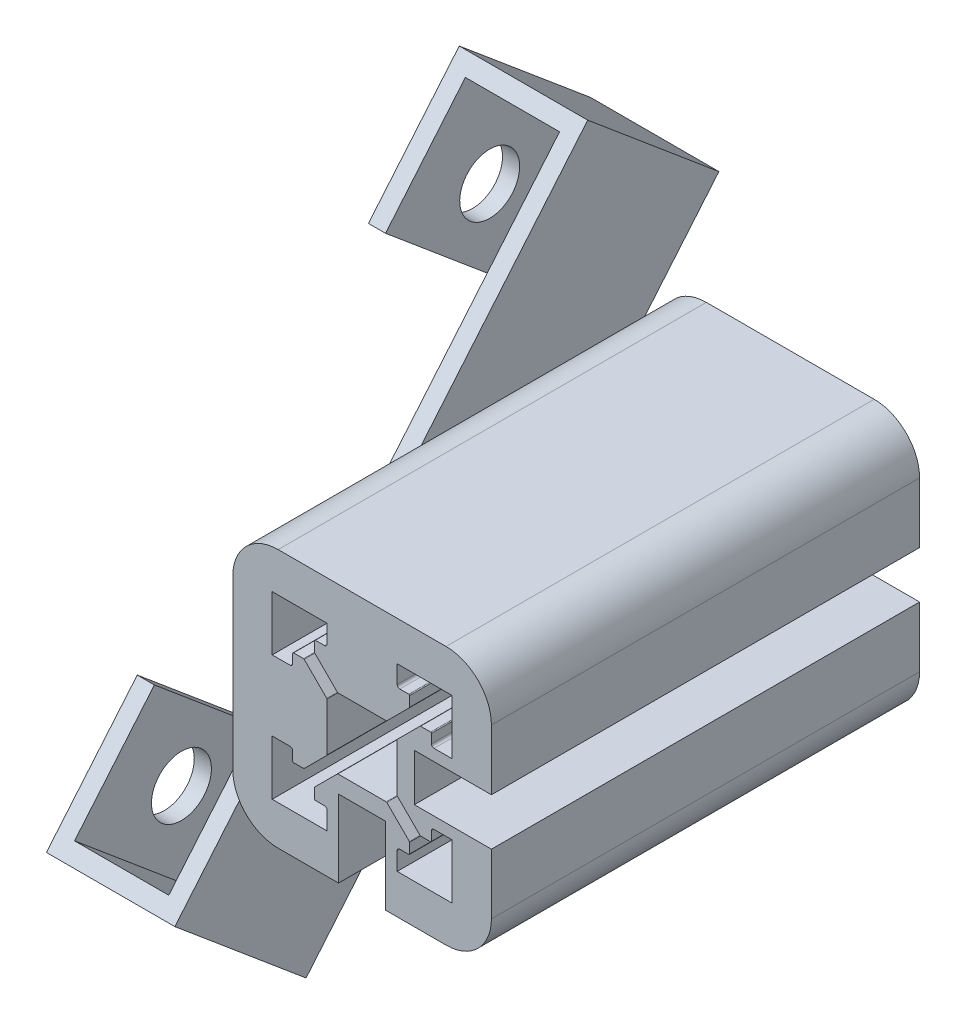
from build123d import *

# Parameters (mm, degrees)
Y_KSEKLIK_EKSTR_ZYON3_DEPTH = 25
Y_KSEKLIK_EKSTR_ZYON4_DEPTH = 15
IZIM11_R                    = 3.5
KES_EKSTR_ZYON3_DEPTH       = 10
KES_EKSTR_ZYON4_DEPTH       = 16
KES_EKSTR_ZYON5_REACH       = 77.444


with BuildPart() as part:
    # Çizim6 → Yükseklik-Ekstrüzyon3 (new, symmetric)
    with BuildSketch(Plane.XY):
        with BuildLine():
            Line((-119.371512251, 18.973770729), (-115.371512251, 18.973770729))
            Line((-115.371512251, 18.973770729), (-110.371512251, 18.973770729))
            Line((-110.371512251, 18.973770729), (-110.371512251, 20.773770729))
            Line((-110.371512251, 20.773770729), (-110.371512251, 26.023770729))
            ThreePointArc((-110.371512251, 26.023770729), (-111.92384631, 29.771436669), (-115.671512251, 31.323770729))
            Line((-115.671512251, 31.323770729), (-120.921512251, 31.323770729))
            Line((-120.921512251, 31.323770729), (-122.721512251, 31.323770729))
            Line((-122.721512251, 31.323770729), (-128.221512251, 31.323770729))
            Line((-128.221512251, 31.323770729), (-130.021512251, 31.323770729))
            Line((-130.021512251, 31.323770729), (-135.271512251, 31.323770729))
            ThreePointArc((-135.271512251, 31.323770729), (-139.019178191, 29.771436669), (-140.571512251, 26.023770729))
            Line((-140.571512251, 26.023770729), (-140.571512251, 20.773770729))
            Line((-140.571512251, 20.773770729), (-140.571512251, 16.223770729))
            Line((-140.571512251, 16.223770729), (-140.571512251, 11.673770729))
            Line((-140.571512251, 11.673770729), (-140.571512251, 6.423770729))
            ThreePointArc((-140.571512251, 6.423770729), (-139.019178191, 2.676104789), (-135.271512251, 1.123770729))
            Line((-135.271512251, 1.123770729), (-130.021512251, 1.123770729))
            Line((-130.021512251, 1.123770729), (-128.221512251, 1.123770729))
            Line((-128.221512251, 1.123770729), (-128.221512251, 6.123770729))
            Line((-128.221512251, 6.123770729), (-128.221512251, 10.123770729))
            Line((-128.221512251, 10.123770729), (-122.721512251, 10.123770729))
            Line((-122.721512251, 10.123770729), (-122.721512251, 6.123770729))
            Line((-122.721512251, 6.123770729), (-122.721512251, 1.123770729))
            Line((-122.721512251, 1.123770729), (-120.921512251, 1.123770729))
            Line((-120.921512251, 1.123770729), (-115.671512251, 1.123770729))
            ThreePointArc((-115.671512251, 1.123770729), (-111.92384631, 2.676104789), (-110.371512251, 6.423770729))
            Line((-110.371512251, 6.423770729), (-110.371512251, 11.673770729))
            Line((-110.371512251, 11.673770729), (-110.371512251, 13.473770729))
            Line((-110.371512251, 13.473770729), (-115.371512251, 13.473770729))
            Line((-115.371512251, 13.473770729), (-119.371512251, 13.473770729))
            Line((-119.371512251, 13.473770729), (-119.371512251, 18.973770729))
        make_face()
        with BuildLine():
            Line((-133.871512251, 20.323770729), (-135.071512251, 20.323770729))
            Line((-135.071512251, 20.323770729), (-135.871512251, 20.323770729))
            Line((-135.871512251, 20.323770729), (-135.971512251, 20.323770729))
            Line((-135.971512251, 20.323770729), (-135.971512251, 26.723770729))
            Line((-135.971512251, 26.723770729), (-129.571512251, 26.723770729))
            Line((-129.571512251, 26.723770729), (-129.571512251, 26.623770729))
            Line((-129.571512251, 26.623770729), (-129.571512251, 25.823770729))
            Line((-129.571512251, 25.823770729), (-129.571512251, 24.623770729))
            ThreePointArc((-129.571512251, 24.623770729), (-129.659380216, 24.411638694), (-129.871512251, 24.323770729))
            Line((-129.871512251, 24.323770729), (-130.921512251, 24.323770729))
            ThreePointArc((-130.921512251, 24.323770729), (-130.992222929, 24.294481407), (-131.021512251, 24.223770729))
            Line((-131.021512251, 24.223770729), (-131.021512251, 23.056613441))
            ThreePointArc((-131.021512251, 23.056613441), (-131.013900204, 23.018345098), (-130.992222929, 22.985902763))
            Line((-130.992222929, 22.985902763), (-128.359380216, 20.353060051))
            ThreePointArc((-128.359380216, 20.353060051), (-128.326937882, 20.331382776), (-128.288669538, 20.323770729))
            Line((-128.288669538, 20.323770729), (-122.654354963, 20.323770729))
            ThreePointArc((-122.654354963, 20.323770729), (-122.61608662, 20.331382776), (-122.583644285, 20.353060051))
            Line((-122.583644285, 20.353060051), (-119.950801573, 22.985902763))
            ThreePointArc((-119.950801573, 22.985902763), (-119.929124298, 23.018345098), (-119.921512251, 23.056613441))
            Line((-119.921512251, 23.056613441), (-119.921512251, 24.223770729))
            ThreePointArc((-119.921512251, 24.223770729), (-119.950801573, 24.294481407), (-120.021512251, 24.323770729))
            Line((-120.021512251, 24.323770729), (-121.071512251, 24.323770729))
            ThreePointArc((-121.071512251, 24.323770729), (-121.283644285, 24.411638694), (-121.371512251, 24.623770729))
            Line((-121.371512251, 24.623770729), (-121.371512251, 25.823770729))
            Line((-121.371512251, 25.823770729), (-121.371512251, 26.323770729))
            Line((-121.371512251, 26.323770729), (-121.371512251, 26.723770729))
            Line((-121.371512251, 26.723770729), (-114.971512251, 26.723770729))
            Line((-114.971512251, 26.723770729), (-114.971512251, 20.323770729))
            Line((-114.971512251, 20.323770729), (-115.371512251, 20.323770729))
            Line((-115.371512251, 20.323770729), (-115.871512251, 20.323770729))
            Line((-115.871512251, 20.323770729), (-117.071512251, 20.323770729))
            ThreePointArc((-117.071512251, 20.323770729), (-117.283644285, 20.411638694), (-117.371512251, 20.623770729))
            Line((-117.371512251, 20.623770729), (-117.371512251, 21.673770729))
            ThreePointArc((-117.371512251, 21.673770729), (-117.400801573, 21.744481407), (-117.471512251, 21.773770729))
            Line((-117.471512251, 21.773770729), (-118.638669538, 21.773770729))
            ThreePointArc((-118.638669538, 21.773770729), (-118.676937882, 21.766158682), (-118.709380216, 21.744481407))
            Line((-118.709380216, 21.744481407), (-121.342222929, 19.111638694))
            ThreePointArc((-121.342222929, 19.111638694), (-121.363900204, 19.07919636), (-121.371512251, 19.040928016))
            Line((-121.371512251, 19.040928016), (-121.371512251, 13.406613441))
            ThreePointArc((-121.371512251, 13.406613441), (-121.363900204, 13.368345098), (-121.342222929, 13.335902763))
            Line((-121.342222929, 13.335902763), (-118.709380216, 10.703060051))
            ThreePointArc((-118.709380216, 10.703060051), (-118.676937882, 10.681382776), (-118.638669538, 10.673770729))
            Line((-118.638669538, 10.673770729), (-117.471512251, 10.673770729))
            ThreePointArc((-117.471512251, 10.673770729), (-117.400801573, 10.703060051), (-117.371512251, 10.773770729))
            Line((-117.371512251, 10.773770729), (-117.371512251, 11.823770729))
            ThreePointArc((-117.371512251, 11.823770729), (-117.283644285, 12.035902763), (-117.071512251, 12.123770729))
            Line((-117.071512251, 12.123770729), (-115.871512251, 12.123770729))
            Line((-115.871512251, 12.123770729), (-115.371512251, 12.123770729))
            Line((-115.371512251, 12.123770729), (-114.971512251, 12.123770729))
            Line((-114.971512251, 12.123770729), (-114.971512251, 5.723770729))
            Line((-114.971512251, 5.723770729), (-121.371512251, 5.723770729))
            Line((-121.371512251, 5.723770729), (-121.371512251, 6.123770729))
            Line((-121.371512251, 6.123770729), (-121.371512251, 6.623770729))
            Line((-121.371512251, 6.623770729), (-121.371512251, 7.823770729))
            ThreePointArc((-121.371512251, 7.823770729), (-121.283644285, 8.035902763), (-121.071512251, 8.123770729))
            Line((-121.071512251, 8.123770729), (-120.021512251, 8.123770729))
            ThreePointArc((-120.021512251, 8.123770729), (-119.950801573, 8.153060051), (-119.921512251, 8.223770729))
            Line((-119.921512251, 8.223770729), (-119.921512251, 9.390928016))
            ThreePointArc((-119.921512251, 9.390928016), (-119.929124298, 9.42919636), (-119.950801573, 9.461638694))
            Line((-119.950801573, 9.461638694), (-122.583644285, 12.094481407))
            ThreePointArc((-122.583644285, 12.094481407), (-122.61608662, 12.116158682), (-122.654354963, 12.123770729))
            Line((-122.654354963, 12.123770729), (-128.288669538, 12.123770729))
            ThreePointArc((-128.288669538, 12.123770729), (-128.326937882, 12.116158682), (-128.359380216, 12.094481407))
            Line((-128.359380216, 12.094481407), (-130.992222929, 9.461638694))
            ThreePointArc((-130.992222929, 9.461638694), (-131.013900204, 9.42919636), (-131.021512251, 9.390928016))
            Line((-131.021512251, 9.390928016), (-131.021512251, 8.223770729))
            ThreePointArc((-131.021512251, 8.223770729), (-130.992222929, 8.153060051), (-130.921512251, 8.123770729))
            Line((-130.921512251, 8.123770729), (-129.871512251, 8.123770729))
            ThreePointArc((-129.871512251, 8.123770729), (-129.659380216, 8.035902763), (-129.571512251, 7.823770729))
            Line((-129.571512251, 7.823770729), (-129.571512251, 6.623770729))
            Line((-129.571512251, 6.623770729), (-129.571512251, 6.123770729))
            Line((-129.571512251, 6.123770729), (-129.571512251, 5.723770729))
            Line((-129.571512251, 5.723770729), (-135.971512251, 5.723770729))
            Line((-135.971512251, 5.723770729), (-135.971512251, 12.123770729))
            Line((-135.971512251, 12.123770729), (-135.571512251, 12.123770729))
            Line((-135.571512251, 12.123770729), (-135.071512251, 12.123770729))
            Line((-135.071512251, 12.123770729), (-133.871512251, 12.123770729))
            ThreePointArc((-133.871512251, 12.123770729), (-133.659380216, 12.035902763), (-133.571512251, 11.823770729))
            Line((-133.571512251, 11.823770729), (-133.571512251, 10.773770729))
            ThreePointArc((-133.571512251, 10.773770729), (-133.542222929, 10.703060051), (-133.471512251, 10.673770729))
            Line((-133.471512251, 10.673770729), (-132.304354963, 10.673770729))
            ThreePointArc((-132.304354963, 10.673770729), (-132.26608662, 10.681382776), (-132.233644285, 10.703060051))
            Line((-132.233644285, 10.703060051), (-129.600801573, 13.335902763))
            ThreePointArc((-129.600801573, 13.335902763), (-129.579124298, 13.368345098), (-129.571512251, 13.406613441))
            Line((-129.571512251, 13.406613441), (-129.571512251, 19.040928016))
            ThreePointArc((-129.571512251, 19.040928016), (-129.579124298, 19.07919636), (-129.600801573, 19.111638694))
            Line((-129.600801573, 19.111638694), (-132.233644285, 21.744481407))
            ThreePointArc((-132.233644285, 21.744481407), (-132.26608662, 21.766158682), (-132.304354963, 21.773770729))
            Line((-132.304354963, 21.773770729), (-133.471512251, 21.773770729))
            ThreePointArc((-133.471512251, 21.773770729), (-133.542222929, 21.744481407), (-133.571512251, 21.673770729))
            Line((-133.571512251, 21.673770729), (-133.571512251, 20.623770729))
            ThreePointArc((-133.571512251, 20.623770729), (-133.659380216, 20.411638694), (-133.871512251, 20.323770729))
        make_face(mode=Mode.SUBTRACT)
    extrude(amount=Y_KSEKLIK_EKSTR_ZYON3_DEPTH, both=True)

    # Çizim8 → Yükseklik-Ekstrüzyon4 (add)
    with BuildSketch(Plane.ZY.offset(140.571512251)):
        Polygon((31.764979794, -6.075019791), (-16.444090932, 51.378313443), (-31.764979794, 38.522561249), (16.444090932, -18.930771985), align=None)
    extrude(amount=Y_KSEKLIK_EKSTR_ZYON4_DEPTH)

    # Çizim11 → Kes-Ekstrüzyon3 (cut)
    with BuildSketch(Plane.ZY.offset(155.571512251)):
        with Locations(Location((17.998053071, -5.225473678, 0), (0, 0, 270))):
            Circle(IZIM11_R)
        with Locations(Location((-17.998053071, 37.673015136, 0), (0, 0, 270))):
            Circle(IZIM11_R)
    extrude(amount=-KES_EKSTR_ZYON3_DEPTH, mode=Mode.SUBTRACT)

    # Çizim12 → Kes-Ekstrüzyon4 (cut)
    with BuildSketch(Plane(origin=(0, 13.13114735, 15.64909203), x_dir=(1, 0, 0), z_dir=(-3.3982743057988955e-15, 0.6427876096865416, 0.7660444431189761))):
        Polygon((-142.571512251, 47.928129413), (-153.571512251, 47.928129413), (-153.571512251, 36.149140278), (-153.571512251, -23.071870587), (-142.571512251, -23.071870587), (-142.571512251, -8.755858334), (-142.571512251, 16.830124537), align=None)
    extrude(amount=-KES_EKSTR_ZYON4_DEPTH, mode=Mode.SUBTRACT)

    # Kes-Ekstrüzyon5: up to this face of the body (flat: up to its plane)
    kes_ekstr_zyon5_end = Plane(part.part.faces().sort_by_distance((-142.571512251, 17.509345948, 1.532088886))[0])
    # Çizim13 → Kes-Ekstrüzyon5 (cut, up to the picked face)
    with BuildSketch(Plane.ZY.offset(155.571512251), mode=Mode.PRIVATE) as kes_ekstr_zyon5_sk1:
        Polygon((-5.838095372, 38.738580131), (-21.158984235, 25.882827937), (5.838095372, -6.291038674), (21.158984235, 6.56471352), align=None)
    kes_ekstr_zyon5_tool1 = split(extrude(kes_ekstr_zyon5_sk1.sketch, amount=-KES_EKSTR_ZYON5_REACH, mode=Mode.PRIVATE), bisect_by=kes_ekstr_zyon5_end, keep=Keep.BOTH, mode=Mode.PRIVATE)
    add(kes_ekstr_zyon5_tool1.solids().sort_by(Axis((-155.571512, 16.223771, 0), (1, 0, 0)))[0], mode=Mode.SUBTRACT)


solid = part.part
